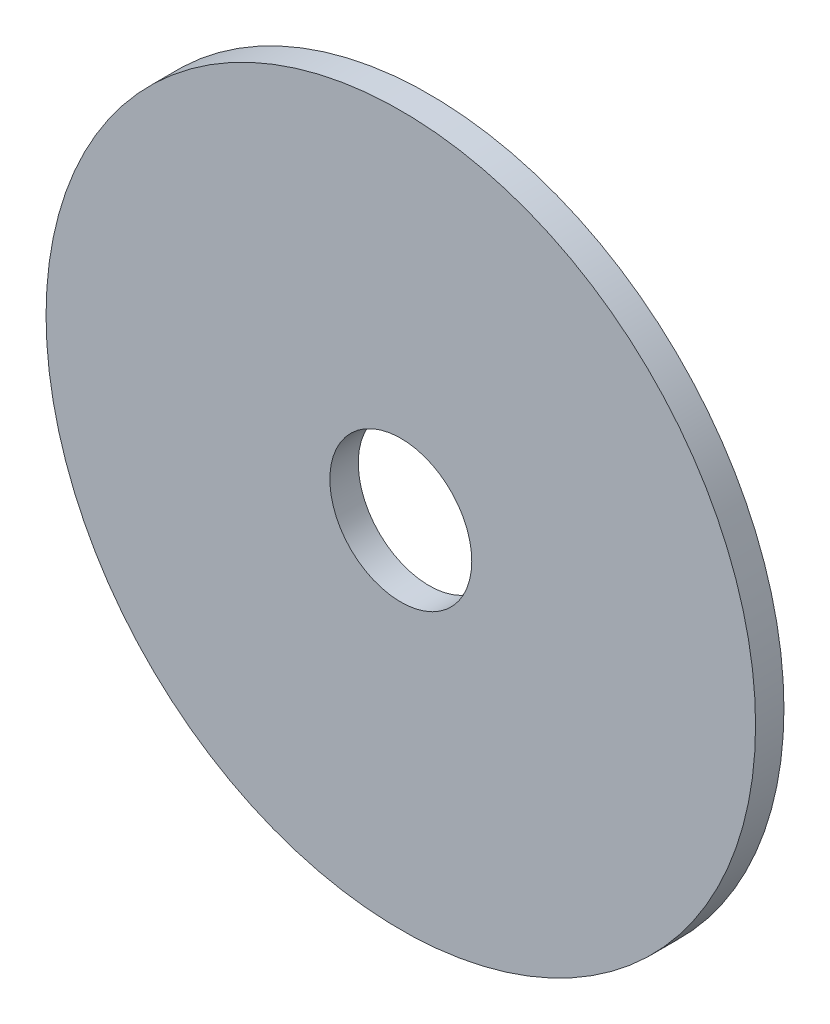
from build123d import *

# Parameters (mm, degrees)
SKETCH1_R           = 7.9375
SKETCH1_R_2         = 1.5875
BOSS_EXTRUDE1_DEPTH = 0.635


with BuildPart() as part:
    # Sketch1 → Boss-Extrude1 (new body)
    with BuildSketch(Plane.XY):
        Circle(SKETCH1_R)
        Circle(SKETCH1_R_2, mode=Mode.SUBTRACT)
    extrude(amount=BOSS_EXTRUDE1_DEPTH)


solid = part.part
